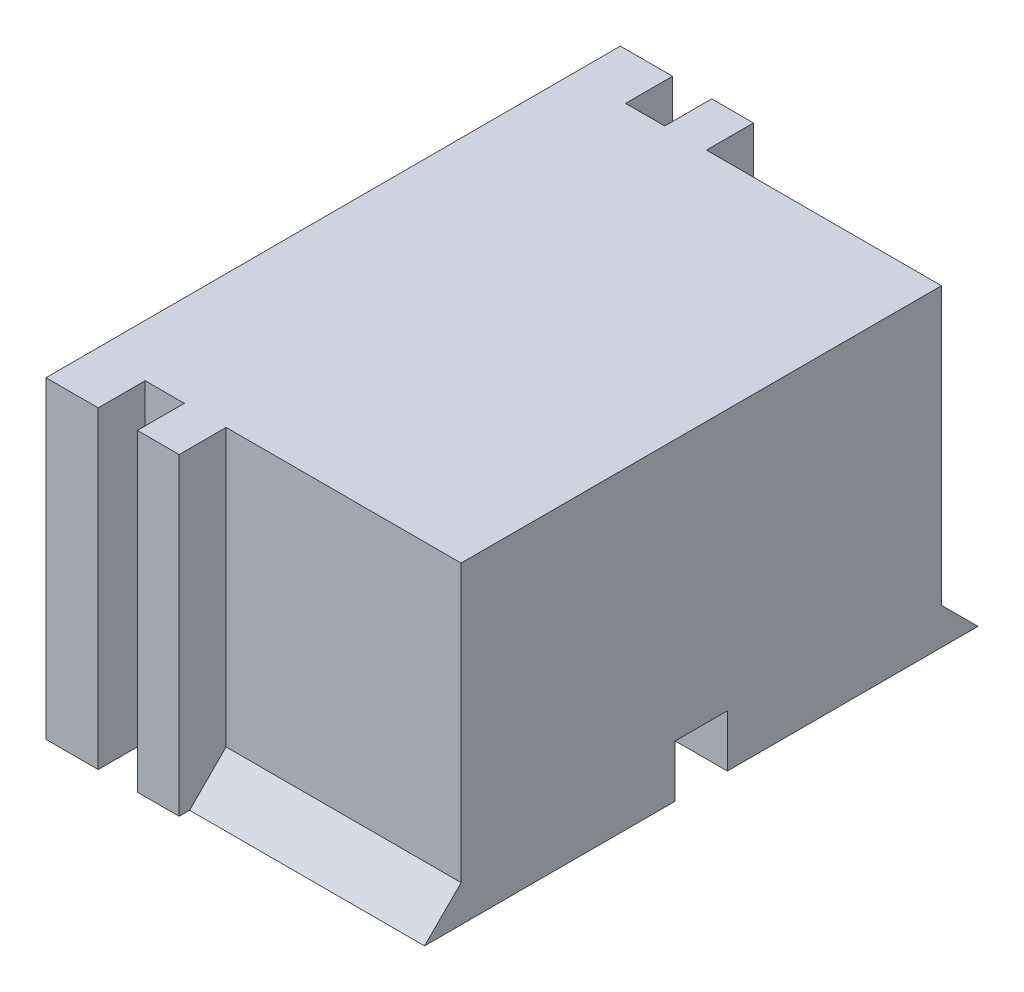
from build123d import *

# Parameters (mm, degrees)
SKETCH_1_W          = 14.1
SKETCH_1_H          = 12
EXTRUDE_1_DEPTH     = 11
SKETCH_2_W          = 1.5
SKETCH_2_H          = 12
CUT_EXTRUDE_1_DEPTH = 1.8
SKETCH_3_W          = 9
SKETCH_3_H          = 12
CUT_EXTRUDE_2_DEPTH = 1.8
EXTRUDE_2_DEPTH     = 9
SKETCH_5_W          = 1
SKETCH_5_H          = 2
CUT_EXTRUDE_3_DEPTH = 12


with BuildPart() as part:
    # Эскиз1 → Бобышка-Вытянуть1 (new body)
    with BuildSketch(Plane.XY):
        with Locations((4.962698413, 0.73968254)):
            Rectangle(SKETCH_1_W, SKETCH_1_H)
    extrude_1 = extrude(amount=EXTRUDE_1_DEPTH)

    # Эскиз2 → Вырез-Вытянуть1 (cut)
    with BuildSketch(Plane(origin=(0, 0, 0), x_dir=(-1, 0, 0), z_dir=(0, 0, -1))):
        with Locations((-0.662698413, 0.73968254)):
            Rectangle(SKETCH_2_W, SKETCH_2_H)
    cut_extrude_1 = extrude(amount=-CUT_EXTRUDE_1_DEPTH, mode=Mode.SUBTRACT)

    # Эскиз3 → Вырез-Вытянуть2 (cut)
    with BuildSketch(Plane(origin=(0, 0, 0), x_dir=(-1, 0, 0), z_dir=(0, 0, -1))):
        with Locations((-7.512698413, 0.73968254)):
            Rectangle(SKETCH_3_W, SKETCH_3_H)
    cut_extrude_2 = extrude(amount=-CUT_EXTRUDE_2_DEPTH, mode=Mode.SUBTRACT)

    # Эскиз4 → Бобышка-Вытянуть2 (add)
    with BuildSketch(Plane(origin=(12.012698413, 0, 0), x_dir=(0, 0, -1), z_dir=(1, 0, 0))):
        Polygon((-1.8, -5.26031746), (-0.4, -5.26031746), (-1.8, -3.86031746), align=None)
    extrude_2 = extrude(amount=-EXTRUDE_2_DEPTH)

    # Эскиз5 → Вырез-Вытянуть3 (cut)
    with BuildSketch(Plane(origin=(12.012698413, 0, 0), x_dir=(0, 0, -1), z_dir=(1, 0, 0))):
        with Locations((-10.5, -4.26031746)):
            Rectangle(SKETCH_5_W, SKETCH_5_H)
    cut_extrude_3 = extrude(amount=-CUT_EXTRUDE_3_DEPTH, mode=Mode.SUBTRACT)

    # Зеркальное отражение1: Бобышка-Вытянуть1, Вырез-Вытянуть1, Вырез-Вытянуть2, Бобышка-Вытянуть2, Вырез-Вытянуть3 across plane
    add(extrude_1.mirror(Plane.XY.offset(11)))
    add(cut_extrude_1.mirror(Plane.XY.offset(11)), mode=Mode.SUBTRACT)
    add(cut_extrude_2.mirror(Plane.XY.offset(11)), mode=Mode.SUBTRACT)
    add(extrude_2.mirror(Plane.XY.offset(11)))
    add(cut_extrude_3.mirror(Plane.XY.offset(11)), mode=Mode.SUBTRACT)


solid = part.part
